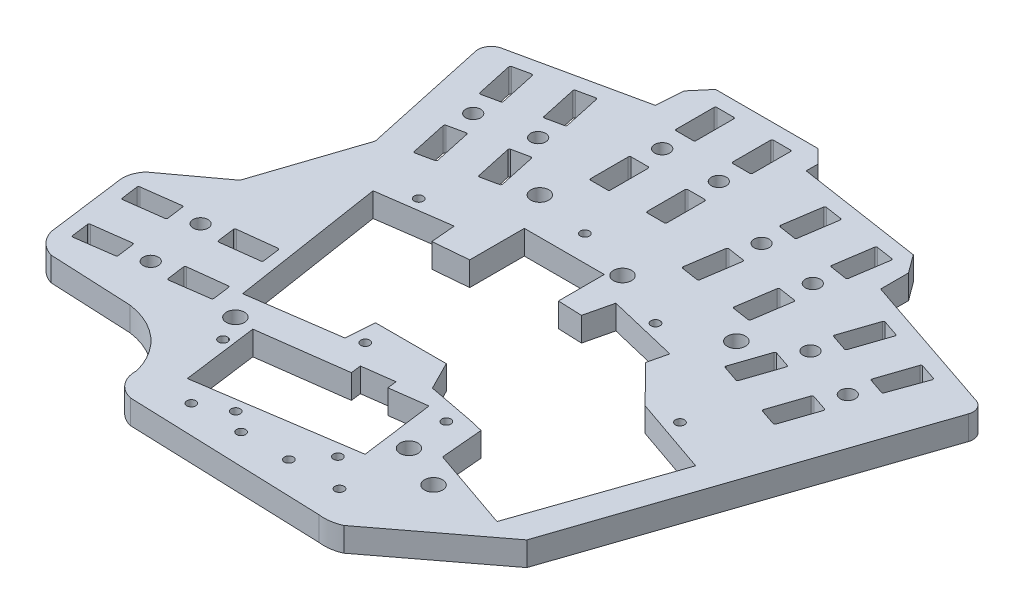
from build123d import *

# Parameters (mm, degrees)
SKETCH1_R           = 1.25
SKETCH1_R_2         = 0.750000001
SKETCH1_R_3         = 1.5
SKETCH1_R_4         = 0.75
SKETCH1_R_5         = 0.749999999
SKETCH1_R_6         = 1.249999996
SKETCH1_R_7         = 0.762710865
SKETCH1_W           = 3.3
SKETCH1_H           = 6.75
BOSS_EXTRUDE1_DEPTH = 4
FILLET2_R           = 0.25


with BuildPart() as part:
    # Sketch1 → Boss-Extrude1 (new body)
    with BuildSketch(Plane(origin=(0, 0, 0), x_dir=(1, 0, 0), z_dir=(0, 1, 0))):
        with BuildLine():
            Line((-0.430572927, 75.733702852), (-0.101645336, 80.23213112))
            Line((-0.101645336, 80.23213112), (2.292258719, 83.051570207))
            Line((2.292258719, 83.051570207), (19.292258719, 83.051570207))
            Line((19.292258719, 83.051570207), (21.569632749, 80.822675372))
            Line((21.569632749, 80.822675372), (21.569632749, 78.853727093))
            Line((21.569632749, 78.853727093), (42.579427231, 75.667658072))
            Line((42.579427231, 75.667658072), (44.801735438, 72.650855206))
            Line((44.801735438, 72.650855206), (44.801735438, 68.010864244))
            Line((44.801735438, 68.010864244), (66.399171257, 60.703965719))
            Line((66.399171257, 60.703965719), (68.854400306, 59.873306483))
            ThreePointArc((68.854400306, 59.873306483), (70.006290859, 58.865192449), (70.107956209, 57.337838559))
            Line((70.107956209, 57.337838559), (51.521051581, 2.399415861))
            Line((51.521051581, 2.399415861), (34.201161842, -10.75013108))
            ThreePointArc((34.201161842, -10.75013108), (32.418371505, -11.267493565), (30.562030462, -11.26929762))
            Line((30.562030462, -11.26929762), (-1.909148554, -10.127561967))
            ThreePointArc((-1.909148554, -10.127561967), (-4.44478516, -8.528167659), (-5.337012181, -5.666097413))
            ThreePointArc((-5.337012181, -5.666097413), (-8.990800967, 0.309772513), (-15.360680848, 3.22281631))
            Line((-15.360680848, 3.22281631), (-29.120495557, 3.860954509))
            ThreePointArc((-29.120495557, 3.860954509), (-31.257817378, 5.125346251), (-32.52220912, 7.262668072))
            Line((-32.52220912, 7.262668072), (-34.212906338, 20.029047384))
            ThreePointArc((-34.212906338, 20.029047384), (-34.146817457, 22.019129459), (-33.180903428, 23.760337229))
            Line((-33.180903428, 23.760337229), (-24.208318686, 30.369933414))
            Line((-24.208318686, 30.369933414), (-18.583594829, 47.282896185))
            Line((-18.583594829, 47.282896185), (-23.206557298, 68.660672803))
            ThreePointArc((-23.206557298, 68.660672803), (-22.827152481, 70.305284389), (-21.395956758, 71.199920675))
            Line((-21.395956758, 71.199920675), (-0.430572927, 75.733702852))
        make_face()
        with Locations((-5.528538157, 61.330767693)):
            Circle(SKETCH1_R, mode=Mode.SUBTRACT)
        with Locations((15.828441724, 70.051570207)):
            Circle(SKETCH1_R, mode=Mode.SUBTRACT)
        with Locations((-14.41984362, 59.408015286)):
            Circle(SKETCH1_R, mode=Mode.SUBTRACT)
        with Locations((12.184683588, 51.392785753)):
            Circle(SKETCH1_R_2, mode=Mode.SUBTRACT)
        with Locations((47.898207779, 53.239406564)):
            Circle(SKETCH1_R, mode=Mode.SUBTRACT)
        with Locations((-4.82644476, 10.231270571)):
            Circle(SKETCH1_R_3, mode=Mode.SUBTRACT)
        with Locations((-2.647090788, 5.998876335)):
            Circle(SKETCH1_R_4, mode=Mode.SUBTRACT)
        with Locations((3.904529718, -5.82919878)):
            Circle(SKETCH1_R_5, mode=Mode.SUBTRACT)
        with Locations((23.789808819, -1.325181731)):
            Circle(SKETCH1_R_4, mode=Mode.SUBTRACT)
        with Locations((28.317536424, 64.681799466)):
            Circle(SKETCH1_R, mode=Mode.SUBTRACT)
        with Locations((40.317035674, 48.475883407)):
            Circle(SKETCH1_R_3, mode=Mode.SUBTRACT)
        with Locations((20.131046287, -5.82919878)):
            Circle(SKETCH1_R_5, mode=Mode.SUBTRACT)
        with Locations((-21.202675307, 20.808869889)):
            Circle(SKETCH1_R, mode=Mode.SUBTRACT)
        with Locations((6.398028421, 70.051570207)):
            Circle(SKETCH1_R, mode=Mode.SUBTRACT)
        with Locations((-19.936500831, 11.248042874)):
            Circle(SKETCH1_R, mode=Mode.SUBTRACT)
        with Locations((38.359034037, 63.159038047)):
            Circle(SKETCH1_R, mode=Mode.SUBTRACT)
        with Locations((8.761031809, -3.29829219)):
            Circle(SKETCH1_R_4, mode=Mode.SUBTRACT)
        with Locations((28.559070872, -5.82919878)):
            Circle(SKETCH1_R_5, mode=Mode.SUBTRACT)
        with Locations((2.879636913, 53.204168852)):
            Circle(SKETCH1_R_3, mode=Mode.SUBTRACT)
        with Locations((21.366925762, 48.475883407)):
            Circle(SKETCH1_R_3, mode=Mode.SUBTRACT)
        with Locations((28.4974894, 5.803294759)):
            Circle(SKETCH1_R_3, mode=Mode.SUBTRACT)
        with Locations((57.276041757, 50.066674309)):
            Circle(SKETCH1_R_6, mode=Mode.SUBTRACT)
        with Locations((12.184683589, -5.82919878)):
            Circle(SKETCH1_R_5, mode=Mode.SUBTRACT)
        with Locations((30.995495452, 44.342964766)):
            Circle(SKETCH1_R_4, mode=Mode.SUBTRACT)
        with Locations((47.314875491, 32.093528394)):
            Circle(SKETCH1_R_4, mode=Mode.SUBTRACT)
        with Locations((-6.677797833, 42.601865546)):
            Circle(SKETCH1_R_4, mode=Mode.SUBTRACT)
        with Locations((9.650488822, 17.369014295)):
            Circle(SKETCH1_R_7, mode=Mode.SUBTRACT)
        with Locations((35.827554666, 2.562132355)):
            Circle(SKETCH1_R_3, mode=Mode.SUBTRACT)
        with Locations((27.75528895, 12.759661315)):
            Circle(SKETCH1_R_4, mode=Mode.SUBTRACT)
        Polygon((0, -2.594690511), (-1.673031432, 9.978056154), (12.812873256, 11.905667877), (12.585594698, 13.613654753), (17.831471972, 14.311713642), (18.038000616, 12.759661315), (24.07903874, 13.563530742), (25.713213265, 1.282791766), align=None, mode=Mode.SUBTRACT)
        Polygon((-18.234867421, 69.325721289), (-15.009423755, 70.023226239), (-13.582709084, 63.425727831), (-16.80815275, 62.728222881), align=None, mode=Mode.SUBTRACT)
        Polygon((-13.796199556, 48.800170686), (-15.222914227, 55.397669094), (-11.997470561, 56.095174044), (-10.57075589, 49.497675636), align=None, mode=Mode.SUBTRACT)
        with Locations((15.828441724, 62.926570207)):
            Rectangle(SKETCH1_W, SKETCH1_H, mode=Mode.SUBTRACT)
        Polygon((-8.042902432, 64.623715755), (-4.817458766, 65.321220705), (-6.244173437, 71.918719114), (-9.469617103, 71.221214164), align=None, mode=Mode.SUBTRACT)
        Polygon((37.289932764, 67.114037726), (40.55263026, 66.619259949), (41.564675714, 73.292959373), (38.301978218, 73.78773715), align=None, mode=Mode.SUBTRACT)
        Polygon((47.537027971, 57.320405112), (49.700254508, 63.714382822), (52.826199166, 62.656805403), (50.662972629, 56.262827694), align=None, mode=Mode.SUBTRACT)
        Polygon((-15.987912577, 9.995745448), (-16.440422315, 13.412626298), (-9.736709043, 14.201757706), (-9.303461033, 10.930321299), align=None, mode=Mode.SUBTRACT)
        Polygon((-30.127363654, 8.221507685), (-30.567032689, 11.541428967), (-23.875458221, 12.427618078), (-23.442210211, 9.156181672), align=None, mode=Mode.SUBTRACT)
        Polygon((-17.267066627, 19.654580645), (-10.569785756, 20.492282817), (-11.003033766, 23.763719223), (-17.706747039, 22.974587831), align=None, mode=Mode.SUBTRACT)
        with Locations((15.828441724, 77.176570207)):
            Rectangle(SKETCH1_W, SKETCH1_H, mode=Mode.SUBTRACT)
        Polygon((28.260480605, 75.31049857), (31.523178101, 74.815720792), (30.511132647, 68.142021369), (27.248435151, 68.636799146), align=None, mode=Mode.SUBTRACT)
        with Locations((6.398028421, 77.176570207)):
            Rectangle(SKETCH1_W, SKETCH1_H, mode=Mode.SUBTRACT)
        Polygon((25.111894748, 54.54787814), (26.123940202, 61.221577564), (29.386637698, 60.726799787), (28.374592244, 54.053100363), align=None, mode=Mode.SUBTRACT)
        Polygon((-4.946665679, 50.713889952), (-1.721222013, 51.411394902), (-3.147936684, 58.00889331), (-6.37338035, 57.31138836), align=None, mode=Mode.SUBTRACT)
        Polygon((36.165437815, 59.698816144), (35.153392361, 53.025116721), (38.416089857, 52.530338943), (39.428135311, 59.204038367), align=None, mode=Mode.SUBTRACT)
        Polygon((-24.701819776, 18.667437336), (-25.135067786, 21.938873743), (-31.826642254, 21.052684631), (-31.393394244, 17.781248225), align=None, mode=Mode.SUBTRACT)
        with Locations((6.398028421, 62.926570207)):
            Rectangle(SKETCH1_W, SKETCH1_H, mode=Mode.SUBTRACT)
        Polygon((42.970216393, 43.822007725), (45.13344293, 50.215985435), (48.259387588, 49.158408017), (46.096161051, 42.764430307), align=None, mode=Mode.SUBTRACT)
        Polygon((56.981169862, 54.125239397), (59.974498694, 53.112528897), (62.26987572, 59.460264266), (59.143931062, 60.517841684), align=None, mode=Mode.SUBTRACT)
        Polygon((57.63722157, 45.98567576), (54.511276904, 47.04325318), (52.348050366, 40.649275471), (55.473995024, 39.591698053), align=None, mode=Mode.SUBTRACT)
        Polygon((19.705691746, 47.103964243), (19.705691746, 42.086481483), (19.705691746, 39.47434437), (23.698679988, 39.317892125), (24.801939778, 43.935464174), (36.608625766, 41.114535391), (35.827554666, 37.845448534), (42.028542128, 31.581784309), (54.888166924, 27.133780716), (46.389102455, 2.562132355), (32.54560266, 7.350447551), (31.933600646, 14.363157311), (29.686328605, 14.900089892), (21.780390901, 16.420473689), (19.407766125, 21.103964243), (7.627578269, 21.103964243), (7.294286784, 16.366132849), (-7.629437293, 14.236146943), (-11.607891113, 39.929957583), (0.241777566, 41.589256111), (0.598028421, 37.507106387), (6.398028421, 38.01327473), (6.398028421, 47.103964243), align=None, mode=Mode.SUBTRACT)
    extrude(amount=BOSS_EXTRUDE1_DEPTH)

    # Fillet2
    fillet2_edges = [part.edges().sort_by_distance(p)[0] for p in [
        (-18.234867421, 2, -69.325721289),
        (-16.80815275, 2, -62.728222881),
        (-13.582709084, 2, -63.425727831),
        (-15.009423755, 2, -70.023226239),
        (-9.469617103, 2, -71.221214164),
        (-8.042902432, 2, -64.623715755),
        (-4.817458766, 2, -65.321220705),
        (-6.244173437, 2, -71.918719114),
        (-13.796199556, 2, -48.800170686),
        (-10.57075589, 2, -49.497675636),
        (-11.997470561, 2, -56.095174044),
        (-15.222914227, 2, -55.397669094),
        (-6.37338035, 2, -57.31138836),
        (-4.946665679, 2, -50.713889952),
        (-1.721222013, 2, -51.411394902),
        (-3.147936684, 2, -58.00889331),
        (4.748028421, 2, -73.801570207),
        (8.048028421, 2, -73.801570207),
        (8.048028421, 2, -80.551570207),
        (4.748028421, 2, -80.551570207),
        (14.178441724, 2, -73.801570207),
        (17.478441724, 2, -73.801570207),
        (17.478441724, 2, -80.551570207),
        (14.178441724, 2, -80.551570207),
        (27.248435151, 2, -68.636799146),
        (30.511132647, 2, -68.142021369),
        (31.523178101, 2, -74.815720792),
        (28.260480605, 2, -75.31049857),
        (4.748028421, 2, -59.551570207),
        (8.048028421, 2, -59.551570207),
        (8.048028421, 2, -66.301570207),
        (4.748028421, 2, -66.301570207),
        (14.178441724, 2, -66.301570207),
        (14.178441724, 2, -59.551570207),
        (17.478441724, 2, -59.551570207),
        (17.478441724, 2, -66.301570207),
        (38.301978218, 2, -73.78773715),
        (37.289932764, 2, -67.114037726),
        (40.55263026, 2, -66.619259949),
        (41.564675714, 2, -73.292959373),
        (25.111894748, 2, -54.54787814),
        (28.374592244, 2, -54.053100363),
        (29.386637698, 2, -60.726799787),
        (26.123940202, 2, -61.221577564),
        (35.153392361, 2, -53.025116721),
        (38.416089857, 2, -52.530338943),
        (39.428135311, 2, -59.204038367),
        (36.165437815, 2, -59.698816144),
        (47.537027971, 2, -57.320405112),
        (50.662972629, 2, -56.262827694),
        (52.826199166, 2, -62.656805403),
        (49.700254508, 2, -63.714382822),
        (42.970216393, 2, -43.822007725),
        (46.096161051, 2, -42.764430307),
        (48.259387588, 2, -49.158408017),
        (45.13344293, 2, -50.215985435),
        (54.511276904, 2, -47.04325318),
        (52.348050366, 2, -40.649275471),
        (55.473995024, 2, -39.591698053),
        (57.63722157, 2, -45.98567576),
        (-30.127363654, 2, -8.221507685),
        (-23.442210211, 2, -9.156181672),
        (-23.875458221, 2, -12.427618078),
        (-30.567032689, 2, -11.541428967),
        (-31.393394244, 2, -17.781248225),
        (-24.701819776, 2, -18.667437336),
        (-25.135067786, 2, -21.938873743),
        (-31.826642254, 2, -21.052684631),
        (-15.987912577, 2, -9.995745448),
        (-9.303461033, 2, -10.930321299),
        (-9.736709043, 2, -14.201757706),
        (-16.440422315, 2, -13.412626298),
        (-10.569785756, 2, -20.492282817),
        (-11.003033766, 2, -23.763719223),
        (-17.706747039, 2, -22.974587831),
        (-17.267066627, 2, -19.654580645),
        (59.974498694, 2, -53.112528897),
        (62.26987572, 2, -59.460264266),
        (59.143931062, 2, -60.517841684),
        (56.981169862, 2, -54.125239397),
    ]]
    fillet(fillet2_edges, radius=FILLET2_R)


solid = part.part
